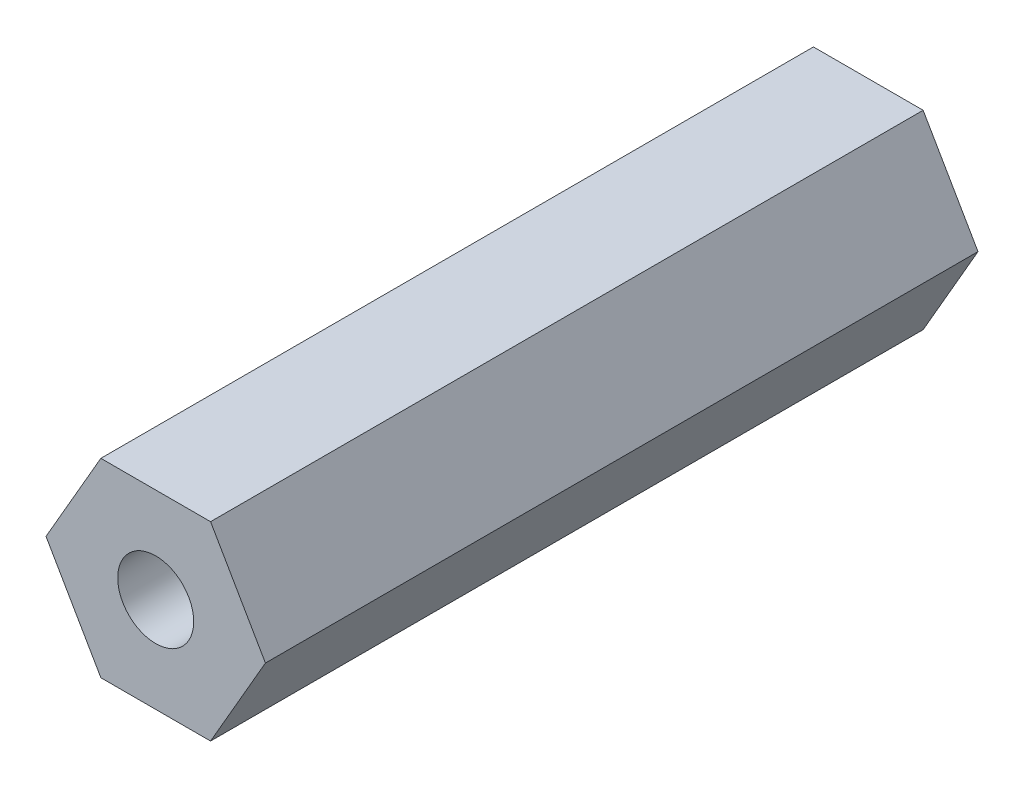
from build123d import *

# Parameters (mm, degrees)
EXTRUDE_1_DEPTH    = 15
HOLE_WIZARD_M2_1_D = 1.6


with BuildPart() as part:
    # 草图1 → 凸台-拉伸1 (new body)
    with BuildSketch(Plane.XY):
        Polygon((1.154700538, 2), (-1.154700538, 2), (-2.309401077, 0), (-1.154700538, -2), (1.154700538, -2), (2.309401077, 0), align=None)
    extrude(amount=EXTRUDE_1_DEPTH)

    # M2 螺纹孔1 (through all)
    with Locations(Plane.XY.offset(15)):
        with Locations((0, 0)):
            Hole(HOLE_WIZARD_M2_1_D / 2)


solid = part.part
